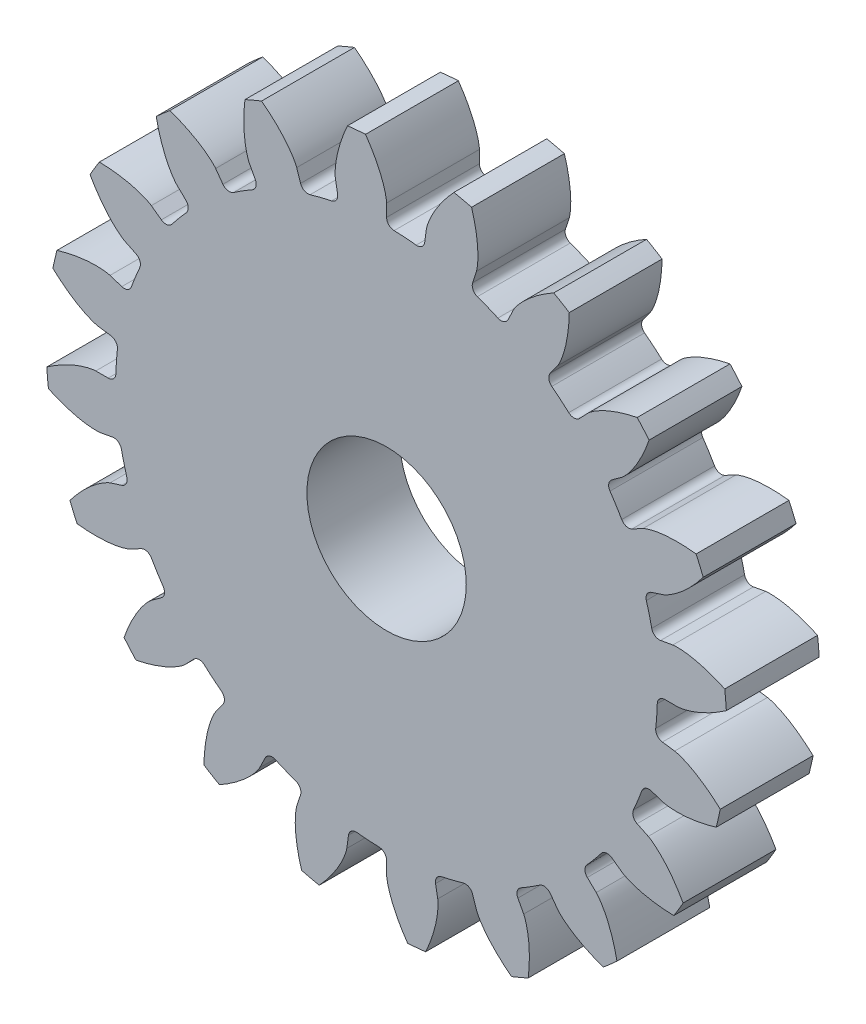
from build123d import *

# Parameters (mm, degrees)
BOSS_EXTRUDE3_DEPTH       = 3
FILLET1_R                 = 0.25
CIRPATTERN8_COUNT         = 20
CIRPATTERN8_COPY_1_DEPTH  = 3
CIRPATTERN8_COPY_2_DEPTH  = 3
CIRPATTERN8_COPY_3_DEPTH  = 3
CIRPATTERN8_COPY_4_DEPTH  = 3
CIRPATTERN8_COPY_5_DEPTH  = 3
CIRPATTERN8_COPY_6_DEPTH  = 3
CIRPATTERN8_COPY_7_DEPTH  = 3
CIRPATTERN8_COPY_8_DEPTH  = 3
CIRPATTERN8_COPY_9_DEPTH  = 3
CIRPATTERN8_COPY_10_DEPTH = 3
CIRPATTERN8_COPY_11_DEPTH = 3
CIRPATTERN8_COPY_12_DEPTH = 3
CIRPATTERN8_COPY_13_DEPTH = 3
CIRPATTERN8_COPY_14_DEPTH = 3
CIRPATTERN8_COPY_15_DEPTH = 3
CIRPATTERN8_COPY_16_DEPTH = 3
CIRPATTERN8_COPY_17_DEPTH = 3
CIRPATTERN8_COPY_18_DEPTH = 3
CIRPATTERN8_COPY_19_DEPTH = 3
FILLET1_OF_CIRPATTERN8_R  = 0.25
SKETCH3_R                 = 2.575
CUT_EXTRUDE2_DEPTH        = 4.0000001


with BuildPart() as part:
    # Sketch1 → Boss-Extrude3 (new body)
    with BuildSketch(Plane.XY):
        with BuildLine():
            Line((8.75, 0), (9.396926208, 0))
            add(Edge.make_bspline(
                [(9.396926208, 0), (9.403873385, 0.000147014), (9.423343335, 0.001014311), (9.460070906, 0.004449694), (9.519753567, 0.012596883), (9.595337479, 0.026698157), (9.692315433, 0.04916848), (9.805467589, 0.081058111), (9.928458206, 0.121729349), (10.060578251, 0.171978374), (10.190725417, 0.227360837), (10.318851863, 0.287431588), (10.444850985, 0.351585639), (10.595383311, 0.434313207), (10.745012763, 0.523787061), (10.861917766, 0.599620812), (10.947597548, 0.658189386), (10.978959632, 0.680033385)],
                knots=[0, 0, 0, 0, 0, 0.005376748, 0.015083688, 0.02853182, 0.046610139, 0.064854849, 0.092110525, 0.119476175, 0.146842495, 0.174208853, 0.201574955, 0.228941013, 0.256307345, 0.307035032, 0.336624535, 0.336624535, 0.336624535, 0.336624535, 0.336624535], degree=4))
            ThreePointArc((10.978959632, 0.680033385), (10.968951272, 0.825898301), (10.957005057, 0.971617307))
            Line((10.957005057, 0.971617307), (8.715799477, 0.772877403))
            ThreePointArc((8.715799477, 0.772877403), (8.741445688, 0.386816868), (8.75, 0))
        make_face()
        with BuildLine():
            ThreePointArc((-8.715799477, -0.772877403), (0.386816868, -8.741445688), (8.75, 0))
            ThreePointArc((8.75, 0), (8.741445688, 0.386816868), (8.715799477, 0.772877403))
            Line((8.715799477, 0.772877403), (-8.715799477, -0.772877403))
        make_face()
        with BuildLine():
            Line((-8.715799477, -0.772877403), (8.715799477, 0.772877403))
            ThreePointArc((8.715799477, 0.772877403), (-0.772877403, 8.715799477), (-8.715799477, -0.772877403))
        make_face()
    boss_extrude3 = extrude(amount=BOSS_EXTRUDE3_DEPTH)

    # Mirror2: Boss-Extrude3 across plane
    add(boss_extrude3.mirror(Plane(origin=(0, 0, 3), x_dir=(0, 0, 1), z_dir=(0.088328846, -0.996091369, 0))))

    # Fillet1
    fillet1_edges = [part.edges().sort_by_distance(p)[0] for p in [
        (8.75, 0, 1.5),
        (8.613465262, 1.539713021, 1.5),
    ]]
    fillet(fillet1_edges, radius=FILLET1_R)

    # CirPattern8: Boss-Extrude3 ×20 about axis
    cirpattern8_axis = Axis((0, 0, 3), (0, 0, -1))
    for i in range(1, CIRPATTERN8_COUNT):
        add(boss_extrude3.rotate(cirpattern8_axis, i * 360 / CIRPATTERN8_COUNT))

    # CirPattern8 copy 1 sketch → CirPattern8 copy 1 (add)
    with BuildSketch(Plane(origin=(0, 0, 0), x_dir=(0.990593115, -0.136840348, 0), z_dir=(0, 0, 1))):
        with BuildLine():
            Line((8.75, 0), (9.396926208, 0))
            add(Edge.make_bspline(
                [(9.396926208, 0), (9.403873385, -0.000147014), (9.423343335, -0.001014311), (9.460070906, -0.004449694), (9.519753567, -0.012596883), (9.595337479, -0.026698157), (9.692315433, -0.04916848), (9.805467589, -0.081058111), (9.928458206, -0.121729349), (10.060578251, -0.171978374), (10.190725417, -0.227360837), (10.318851863, -0.287431588), (10.444850985, -0.351585639), (10.595383311, -0.434313207), (10.745012763, -0.523787061), (10.861917766, -0.599620812), (10.947597548, -0.658189386), (10.978959632, -0.680033385)],
                knots=[0, 0, 0, 0, 0, 0.005376748, 0.015083688, 0.02853182, 0.046610139, 0.064854849, 0.092110525, 0.119476175, 0.146842495, 0.174208853, 0.201574955, 0.228941013, 0.256307345, 0.307035032, 0.336624535, 0.336624535, 0.336624535, 0.336624535, 0.336624535], degree=4))
            ThreePointArc((10.978959632, -0.680033385), (10.968951272, -0.825898301), (10.957005057, -0.971617307))
            Line((10.957005057, -0.971617307), (8.715799477, -0.772877403))
            ThreePointArc((8.715799477, -0.772877403), (8.741445688, -0.386816868), (8.75, 0))
        make_face()
        with BuildLine():
            ThreePointArc((-8.715799477, 0.772877403), (0.386816868, 8.741445688), (8.75, 0))
            ThreePointArc((8.75, 0), (8.741445688, -0.386816868), (8.715799477, -0.772877403))
            Line((8.715799477, -0.772877403), (-8.715799477, 0.772877403))
        make_face()
        with BuildLine():
            Line((-8.715799477, 0.772877403), (8.715799477, -0.772877403))
            ThreePointArc((8.715799477, -0.772877403), (-0.772877403, -8.715799477), (-8.715799477, 0.772877403))
        make_face()
    extrude(amount=CIRPATTERN8_COPY_1_DEPTH)

    # CirPattern8 copy 2 sketch → CirPattern8 copy 2 (add)
    with BuildSketch(Plane(origin=(0, 0, 0), x_dir=(0.899824044, -0.436253012, 0), z_dir=(0, 0, 1))):
        with BuildLine():
            Line((8.75, 0), (9.396926208, 0))
            add(Edge.make_bspline(
                [(9.396926208, 0), (9.403873385, -0.000147014), (9.423343335, -0.001014311), (9.460070906, -0.004449694), (9.519753567, -0.012596883), (9.595337479, -0.026698157), (9.692315433, -0.04916848), (9.805467589, -0.081058111), (9.928458206, -0.121729349), (10.060578251, -0.171978374), (10.190725417, -0.227360837), (10.318851863, -0.287431588), (10.444850985, -0.351585639), (10.595383311, -0.434313207), (10.745012763, -0.523787061), (10.861917766, -0.599620812), (10.947597548, -0.658189386), (10.978959632, -0.680033385)],
                knots=[0, 0, 0, 0, 0, 0.005376748, 0.015083688, 0.02853182, 0.046610139, 0.064854849, 0.092110525, 0.119476175, 0.146842495, 0.174208853, 0.201574955, 0.228941013, 0.256307345, 0.307035032, 0.336624535, 0.336624535, 0.336624535, 0.336624535, 0.336624535], degree=4))
            ThreePointArc((10.978959632, -0.680033385), (10.968951272, -0.825898301), (10.957005057, -0.971617307))
            Line((10.957005057, -0.971617307), (8.715799477, -0.772877403))
            ThreePointArc((8.715799477, -0.772877403), (8.741445688, -0.386816868), (8.75, 0))
        make_face()
        with BuildLine():
            ThreePointArc((-8.715799477, 0.772877403), (0.386816868, 8.741445688), (8.75, 0))
            ThreePointArc((8.75, 0), (8.741445688, -0.386816868), (8.715799477, -0.772877403))
            Line((8.715799477, -0.772877403), (-8.715799477, 0.772877403))
        make_face()
        with BuildLine():
            Line((-8.715799477, 0.772877403), (8.715799477, -0.772877403))
            ThreePointArc((8.715799477, -0.772877403), (-0.772877403, -8.715799477), (-8.715799477, 0.772877403))
        make_face()
    extrude(amount=CIRPATTERN8_COPY_2_DEPTH)

    # CirPattern8 copy 3 sketch → CirPattern8 copy 3 (add)
    with BuildSketch(Plane(origin=(0, 0, 0), x_dir=(0.720973926, -0.692962191, 0), z_dir=(0, 0, 1))):
        with BuildLine():
            Line((8.75, 0), (9.396926208, 0))
            add(Edge.make_bspline(
                [(9.396926208, 0), (9.403873385, -0.000147014), (9.423343335, -0.001014311), (9.460070906, -0.004449694), (9.519753567, -0.012596883), (9.595337479, -0.026698157), (9.692315433, -0.04916848), (9.805467589, -0.081058111), (9.928458206, -0.121729349), (10.060578251, -0.171978374), (10.190725417, -0.227360837), (10.318851863, -0.287431588), (10.444850985, -0.351585639), (10.595383311, -0.434313207), (10.745012763, -0.523787061), (10.861917766, -0.599620812), (10.947597548, -0.658189386), (10.978959632, -0.680033385)],
                knots=[0, 0, 0, 0, 0, 0.005376748, 0.015083688, 0.02853182, 0.046610139, 0.064854849, 0.092110525, 0.119476175, 0.146842495, 0.174208853, 0.201574955, 0.228941013, 0.256307345, 0.307035032, 0.336624535, 0.336624535, 0.336624535, 0.336624535, 0.336624535], degree=4))
            ThreePointArc((10.978959632, -0.680033385), (10.968951272, -0.825898301), (10.957005057, -0.971617307))
            Line((10.957005057, -0.971617307), (8.715799477, -0.772877403))
            ThreePointArc((8.715799477, -0.772877403), (8.741445688, -0.386816868), (8.75, 0))
        make_face()
        with BuildLine():
            ThreePointArc((-8.715799477, 0.772877403), (0.386816868, 8.741445688), (8.75, 0))
            ThreePointArc((8.75, 0), (8.741445688, -0.386816868), (8.715799477, -0.772877403))
            Line((8.715799477, -0.772877403), (-8.715799477, 0.772877403))
        make_face()
        with BuildLine():
            Line((-8.715799477, 0.772877403), (8.715799477, -0.772877403))
            ThreePointArc((8.715799477, -0.772877403), (-0.772877403, -8.715799477), (-8.715799477, 0.772877403))
        make_face()
    extrude(amount=CIRPATTERN8_COPY_3_DEPTH)

    # CirPattern8 copy 4 sketch → CirPattern8 copy 4 (add)
    with BuildSketch(Plane(origin=(0, 0, 0), x_dir=(0.471549857, -0.881839403, 0), z_dir=(0, 0, 1))):
        with BuildLine():
            Line((8.75, 0), (9.396926208, 0))
            add(Edge.make_bspline(
                [(9.396926208, 0), (9.403873385, -0.000147014), (9.423343335, -0.001014311), (9.460070906, -0.004449694), (9.519753567, -0.012596883), (9.595337479, -0.026698157), (9.692315433, -0.04916848), (9.805467589, -0.081058111), (9.928458206, -0.121729349), (10.060578251, -0.171978374), (10.190725417, -0.227360837), (10.318851863, -0.287431588), (10.444850985, -0.351585639), (10.595383311, -0.434313207), (10.745012763, -0.523787061), (10.861917766, -0.599620812), (10.947597548, -0.658189386), (10.978959632, -0.680033385)],
                knots=[0, 0, 0, 0, 0, 0.005376748, 0.015083688, 0.02853182, 0.046610139, 0.064854849, 0.092110525, 0.119476175, 0.146842495, 0.174208853, 0.201574955, 0.228941013, 0.256307345, 0.307035032, 0.336624535, 0.336624535, 0.336624535, 0.336624535, 0.336624535], degree=4))
            ThreePointArc((10.978959632, -0.680033385), (10.968951272, -0.825898301), (10.957005057, -0.971617307))
            Line((10.957005057, -0.971617307), (8.715799477, -0.772877403))
            ThreePointArc((8.715799477, -0.772877403), (8.741445688, -0.386816868), (8.75, 0))
        make_face()
        with BuildLine():
            ThreePointArc((-8.715799477, 0.772877403), (0.386816868, 8.741445688), (8.75, 0))
            ThreePointArc((8.75, 0), (8.741445688, -0.386816868), (8.715799477, -0.772877403))
            Line((8.715799477, -0.772877403), (-8.715799477, 0.772877403))
        make_face()
        with BuildLine():
            Line((-8.715799477, 0.772877403), (8.715799477, -0.772877403))
            ThreePointArc((8.715799477, -0.772877403), (-0.772877403, -8.715799477), (-8.715799477, 0.772877403))
        make_face()
    extrude(amount=CIRPATTERN8_COPY_4_DEPTH)

    # CirPattern8 copy 5 sketch → CirPattern8 copy 5 (add)
    with BuildSketch(Plane(origin=(0, 0, 0), x_dir=(0.175967202, -0.98439603, 0), z_dir=(0, 0, 1))):
        with BuildLine():
            Line((8.75, 0), (9.396926208, 0))
            add(Edge.make_bspline(
                [(9.396926208, 0), (9.403873385, -0.000147014), (9.423343335, -0.001014311), (9.460070906, -0.004449694), (9.519753567, -0.012596883), (9.595337479, -0.026698157), (9.692315433, -0.04916848), (9.805467589, -0.081058111), (9.928458206, -0.121729349), (10.060578251, -0.171978374), (10.190725417, -0.227360837), (10.318851863, -0.287431588), (10.444850985, -0.351585639), (10.595383311, -0.434313207), (10.745012763, -0.523787061), (10.861917766, -0.599620812), (10.947597548, -0.658189386), (10.978959632, -0.680033385)],
                knots=[0, 0, 0, 0, 0, 0.005376748, 0.015083688, 0.02853182, 0.046610139, 0.064854849, 0.092110525, 0.119476175, 0.146842495, 0.174208853, 0.201574955, 0.228941013, 0.256307345, 0.307035032, 0.336624535, 0.336624535, 0.336624535, 0.336624535, 0.336624535], degree=4))
            ThreePointArc((10.978959632, -0.680033385), (10.968951272, -0.825898301), (10.957005057, -0.971617307))
            Line((10.957005057, -0.971617307), (8.715799477, -0.772877403))
            ThreePointArc((8.715799477, -0.772877403), (8.741445688, -0.386816868), (8.75, 0))
        make_face()
        with BuildLine():
            ThreePointArc((-8.715799477, 0.772877403), (0.386816868, 8.741445688), (8.75, 0))
            ThreePointArc((8.75, 0), (8.741445688, -0.386816868), (8.715799477, -0.772877403))
            Line((8.715799477, -0.772877403), (-8.715799477, 0.772877403))
        make_face()
        with BuildLine():
            Line((-8.715799477, 0.772877403), (8.715799477, -0.772877403))
            ThreePointArc((8.715799477, -0.772877403), (-0.772877403, -8.715799477), (-8.715799477, 0.772877403))
        make_face()
    extrude(amount=CIRPATTERN8_COPY_5_DEPTH)

    # CirPattern8 copy 6 sketch → CirPattern8 copy 6 (add)
    with BuildSketch(Plane(origin=(0, 0, 0), x_dir=(-0.136840348, -0.990593115, 0), z_dir=(0, 0, 1))):
        with BuildLine():
            Line((8.75, 0), (9.396926208, 0))
            add(Edge.make_bspline(
                [(9.396926208, 0), (9.403873385, -0.000147014), (9.423343335, -0.001014311), (9.460070906, -0.004449694), (9.519753567, -0.012596883), (9.595337479, -0.026698157), (9.692315433, -0.04916848), (9.805467589, -0.081058111), (9.928458206, -0.121729349), (10.060578251, -0.171978374), (10.190725417, -0.227360837), (10.318851863, -0.287431588), (10.444850985, -0.351585639), (10.595383311, -0.434313207), (10.745012763, -0.523787061), (10.861917766, -0.599620812), (10.947597548, -0.658189386), (10.978959632, -0.680033385)],
                knots=[0, 0, 0, 0, 0, 0.005376748, 0.015083688, 0.02853182, 0.046610139, 0.064854849, 0.092110525, 0.119476175, 0.146842495, 0.174208853, 0.201574955, 0.228941013, 0.256307345, 0.307035032, 0.336624535, 0.336624535, 0.336624535, 0.336624535, 0.336624535], degree=4))
            ThreePointArc((10.978959632, -0.680033385), (10.968951272, -0.825898301), (10.957005057, -0.971617307))
            Line((10.957005057, -0.971617307), (8.715799477, -0.772877403))
            ThreePointArc((8.715799477, -0.772877403), (8.741445688, -0.386816868), (8.75, 0))
        make_face()
        with BuildLine():
            ThreePointArc((-8.715799477, 0.772877403), (0.386816868, 8.741445688), (8.75, 0))
            ThreePointArc((8.75, 0), (8.741445688, -0.386816868), (8.715799477, -0.772877403))
            Line((8.715799477, -0.772877403), (-8.715799477, 0.772877403))
        make_face()
        with BuildLine():
            Line((-8.715799477, 0.772877403), (8.715799477, -0.772877403))
            ThreePointArc((8.715799477, -0.772877403), (-0.772877403, -8.715799477), (-8.715799477, 0.772877403))
        make_face()
    extrude(amount=CIRPATTERN8_COPY_6_DEPTH)

    # CirPattern8 copy 7 sketch → CirPattern8 copy 7 (add)
    with BuildSketch(Plane(origin=(0, 0, 0), x_dir=(-0.436253012, -0.899824044, 0), z_dir=(0, 0, 1))):
        with BuildLine():
            Line((8.75, 0), (9.396926208, 0))
            add(Edge.make_bspline(
                [(9.396926208, 0), (9.403873385, -0.000147014), (9.423343335, -0.001014311), (9.460070906, -0.004449694), (9.519753567, -0.012596883), (9.595337479, -0.026698157), (9.692315433, -0.04916848), (9.805467589, -0.081058111), (9.928458206, -0.121729349), (10.060578251, -0.171978374), (10.190725417, -0.227360837), (10.318851863, -0.287431588), (10.444850985, -0.351585639), (10.595383311, -0.434313207), (10.745012763, -0.523787061), (10.861917766, -0.599620812), (10.947597548, -0.658189386), (10.978959632, -0.680033385)],
                knots=[0, 0, 0, 0, 0, 0.005376748, 0.015083688, 0.02853182, 0.046610139, 0.064854849, 0.092110525, 0.119476175, 0.146842495, 0.174208853, 0.201574955, 0.228941013, 0.256307345, 0.307035032, 0.336624535, 0.336624535, 0.336624535, 0.336624535, 0.336624535], degree=4))
            ThreePointArc((10.978959632, -0.680033385), (10.968951272, -0.825898301), (10.957005057, -0.971617307))
            Line((10.957005057, -0.971617307), (8.715799477, -0.772877403))
            ThreePointArc((8.715799477, -0.772877403), (8.741445688, -0.386816868), (8.75, 0))
        make_face()
        with BuildLine():
            ThreePointArc((-8.715799477, 0.772877403), (0.386816868, 8.741445688), (8.75, 0))
            ThreePointArc((8.75, 0), (8.741445688, -0.386816868), (8.715799477, -0.772877403))
            Line((8.715799477, -0.772877403), (-8.715799477, 0.772877403))
        make_face()
        with BuildLine():
            Line((-8.715799477, 0.772877403), (8.715799477, -0.772877403))
            ThreePointArc((8.715799477, -0.772877403), (-0.772877403, -8.715799477), (-8.715799477, 0.772877403))
        make_face()
    extrude(amount=CIRPATTERN8_COPY_7_DEPTH)

    # CirPattern8 copy 8 sketch → CirPattern8 copy 8 (add)
    with BuildSketch(Plane(origin=(0, 0, 0), x_dir=(-0.692962191, -0.720973926, 0), z_dir=(0, 0, 1))):
        with BuildLine():
            Line((8.75, 0), (9.396926208, 0))
            add(Edge.make_bspline(
                [(9.396926208, 0), (9.403873385, -0.000147014), (9.423343335, -0.001014311), (9.460070906, -0.004449694), (9.519753567, -0.012596883), (9.595337479, -0.026698157), (9.692315433, -0.04916848), (9.805467589, -0.081058111), (9.928458206, -0.121729349), (10.060578251, -0.171978374), (10.190725417, -0.227360837), (10.318851863, -0.287431588), (10.444850985, -0.351585639), (10.595383311, -0.434313207), (10.745012763, -0.523787061), (10.861917766, -0.599620812), (10.947597548, -0.658189386), (10.978959632, -0.680033385)],
                knots=[0, 0, 0, 0, 0, 0.005376748, 0.015083688, 0.02853182, 0.046610139, 0.064854849, 0.092110525, 0.119476175, 0.146842495, 0.174208853, 0.201574955, 0.228941013, 0.256307345, 0.307035032, 0.336624535, 0.336624535, 0.336624535, 0.336624535, 0.336624535], degree=4))
            ThreePointArc((10.978959632, -0.680033385), (10.968951272, -0.825898301), (10.957005057, -0.971617307))
            Line((10.957005057, -0.971617307), (8.715799477, -0.772877403))
            ThreePointArc((8.715799477, -0.772877403), (8.741445688, -0.386816868), (8.75, 0))
        make_face()
        with BuildLine():
            ThreePointArc((-8.715799477, 0.772877403), (0.386816868, 8.741445688), (8.75, 0))
            ThreePointArc((8.75, 0), (8.741445688, -0.386816868), (8.715799477, -0.772877403))
            Line((8.715799477, -0.772877403), (-8.715799477, 0.772877403))
        make_face()
        with BuildLine():
            Line((-8.715799477, 0.772877403), (8.715799477, -0.772877403))
            ThreePointArc((8.715799477, -0.772877403), (-0.772877403, -8.715799477), (-8.715799477, 0.772877403))
        make_face()
    extrude(amount=CIRPATTERN8_COPY_8_DEPTH)

    # CirPattern8 copy 9 sketch → CirPattern8 copy 9 (add)
    with BuildSketch(Plane(origin=(0, 0, 0), x_dir=(-0.881839403, -0.471549857, 0), z_dir=(0, 0, 1))):
        with BuildLine():
            Line((8.75, 0), (9.396926208, 0))
            add(Edge.make_bspline(
                [(9.396926208, 0), (9.403873385, -0.000147014), (9.423343335, -0.001014311), (9.460070906, -0.004449694), (9.519753567, -0.012596883), (9.595337479, -0.026698157), (9.692315433, -0.04916848), (9.805467589, -0.081058111), (9.928458206, -0.121729349), (10.060578251, -0.171978374), (10.190725417, -0.227360837), (10.318851863, -0.287431588), (10.444850985, -0.351585639), (10.595383311, -0.434313207), (10.745012763, -0.523787061), (10.861917766, -0.599620812), (10.947597548, -0.658189386), (10.978959632, -0.680033385)],
                knots=[0, 0, 0, 0, 0, 0.005376748, 0.015083688, 0.02853182, 0.046610139, 0.064854849, 0.092110525, 0.119476175, 0.146842495, 0.174208853, 0.201574955, 0.228941013, 0.256307345, 0.307035032, 0.336624535, 0.336624535, 0.336624535, 0.336624535, 0.336624535], degree=4))
            ThreePointArc((10.978959632, -0.680033385), (10.968951272, -0.825898301), (10.957005057, -0.971617307))
            Line((10.957005057, -0.971617307), (8.715799477, -0.772877403))
            ThreePointArc((8.715799477, -0.772877403), (8.741445688, -0.386816868), (8.75, 0))
        make_face()
        with BuildLine():
            ThreePointArc((-8.715799477, 0.772877403), (0.386816868, 8.741445688), (8.75, 0))
            ThreePointArc((8.75, 0), (8.741445688, -0.386816868), (8.715799477, -0.772877403))
            Line((8.715799477, -0.772877403), (-8.715799477, 0.772877403))
        make_face()
        with BuildLine():
            Line((-8.715799477, 0.772877403), (8.715799477, -0.772877403))
            ThreePointArc((8.715799477, -0.772877403), (-0.772877403, -8.715799477), (-8.715799477, 0.772877403))
        make_face()
    extrude(amount=CIRPATTERN8_COPY_9_DEPTH)

    # CirPattern8 copy 10 sketch → CirPattern8 copy 10 (add)
    with BuildSketch(Plane(origin=(0, 0, 0), x_dir=(-0.98439603, -0.175967202, 0), z_dir=(0, 0, 1))):
        with BuildLine():
            Line((8.75, 0), (9.396926208, 0))
            add(Edge.make_bspline(
                [(9.396926208, 0), (9.403873385, -0.000147014), (9.423343335, -0.001014311), (9.460070906, -0.004449694), (9.519753567, -0.012596883), (9.595337479, -0.026698157), (9.692315433, -0.04916848), (9.805467589, -0.081058111), (9.928458206, -0.121729349), (10.060578251, -0.171978374), (10.190725417, -0.227360837), (10.318851863, -0.287431588), (10.444850985, -0.351585639), (10.595383311, -0.434313207), (10.745012763, -0.523787061), (10.861917766, -0.599620812), (10.947597548, -0.658189386), (10.978959632, -0.680033385)],
                knots=[0, 0, 0, 0, 0, 0.005376748, 0.015083688, 0.02853182, 0.046610139, 0.064854849, 0.092110525, 0.119476175, 0.146842495, 0.174208853, 0.201574955, 0.228941013, 0.256307345, 0.307035032, 0.336624535, 0.336624535, 0.336624535, 0.336624535, 0.336624535], degree=4))
            ThreePointArc((10.978959632, -0.680033385), (10.968951272, -0.825898301), (10.957005057, -0.971617307))
            Line((10.957005057, -0.971617307), (8.715799477, -0.772877403))
            ThreePointArc((8.715799477, -0.772877403), (8.741445688, -0.386816868), (8.75, 0))
        make_face()
        with BuildLine():
            ThreePointArc((-8.715799477, 0.772877403), (0.386816868, 8.741445688), (8.75, 0))
            ThreePointArc((8.75, 0), (8.741445688, -0.386816868), (8.715799477, -0.772877403))
            Line((8.715799477, -0.772877403), (-8.715799477, 0.772877403))
        make_face()
        with BuildLine():
            Line((-8.715799477, 0.772877403), (8.715799477, -0.772877403))
            ThreePointArc((8.715799477, -0.772877403), (-0.772877403, -8.715799477), (-8.715799477, 0.772877403))
        make_face()
    extrude(amount=CIRPATTERN8_COPY_10_DEPTH)

    # CirPattern8 copy 11 sketch → CirPattern8 copy 11 (add)
    with BuildSketch(Plane(origin=(0, 0, 0), x_dir=(-0.990593115, 0.136840348, 0), z_dir=(0, 0, 1))):
        with BuildLine():
            Line((8.75, 0), (9.396926208, 0))
            add(Edge.make_bspline(
                [(9.396926208, 0), (9.403873385, -0.000147014), (9.423343335, -0.001014311), (9.460070906, -0.004449694), (9.519753567, -0.012596883), (9.595337479, -0.026698157), (9.692315433, -0.04916848), (9.805467589, -0.081058111), (9.928458206, -0.121729349), (10.060578251, -0.171978374), (10.190725417, -0.227360837), (10.318851863, -0.287431588), (10.444850985, -0.351585639), (10.595383311, -0.434313207), (10.745012763, -0.523787061), (10.861917766, -0.599620812), (10.947597548, -0.658189386), (10.978959632, -0.680033385)],
                knots=[0, 0, 0, 0, 0, 0.005376748, 0.015083688, 0.02853182, 0.046610139, 0.064854849, 0.092110525, 0.119476175, 0.146842495, 0.174208853, 0.201574955, 0.228941013, 0.256307345, 0.307035032, 0.336624535, 0.336624535, 0.336624535, 0.336624535, 0.336624535], degree=4))
            ThreePointArc((10.978959632, -0.680033385), (10.968951272, -0.825898301), (10.957005057, -0.971617307))
            Line((10.957005057, -0.971617307), (8.715799477, -0.772877403))
            ThreePointArc((8.715799477, -0.772877403), (8.741445688, -0.386816868), (8.75, 0))
        make_face()
        with BuildLine():
            ThreePointArc((-8.715799477, 0.772877403), (0.386816868, 8.741445688), (8.75, 0))
            ThreePointArc((8.75, 0), (8.741445688, -0.386816868), (8.715799477, -0.772877403))
            Line((8.715799477, -0.772877403), (-8.715799477, 0.772877403))
        make_face()
        with BuildLine():
            Line((-8.715799477, 0.772877403), (8.715799477, -0.772877403))
            ThreePointArc((8.715799477, -0.772877403), (-0.772877403, -8.715799477), (-8.715799477, 0.772877403))
        make_face()
    extrude(amount=CIRPATTERN8_COPY_11_DEPTH)

    # CirPattern8 copy 12 sketch → CirPattern8 copy 12 (add)
    with BuildSketch(Plane(origin=(0, 0, 0), x_dir=(-0.899824044, 0.436253012, 0), z_dir=(0, 0, 1))):
        with BuildLine():
            Line((8.75, 0), (9.396926208, 0))
            add(Edge.make_bspline(
                [(9.396926208, 0), (9.403873385, -0.000147014), (9.423343335, -0.001014311), (9.460070906, -0.004449694), (9.519753567, -0.012596883), (9.595337479, -0.026698157), (9.692315433, -0.04916848), (9.805467589, -0.081058111), (9.928458206, -0.121729349), (10.060578251, -0.171978374), (10.190725417, -0.227360837), (10.318851863, -0.287431588), (10.444850985, -0.351585639), (10.595383311, -0.434313207), (10.745012763, -0.523787061), (10.861917766, -0.599620812), (10.947597548, -0.658189386), (10.978959632, -0.680033385)],
                knots=[0, 0, 0, 0, 0, 0.005376748, 0.015083688, 0.02853182, 0.046610139, 0.064854849, 0.092110525, 0.119476175, 0.146842495, 0.174208853, 0.201574955, 0.228941013, 0.256307345, 0.307035032, 0.336624535, 0.336624535, 0.336624535, 0.336624535, 0.336624535], degree=4))
            ThreePointArc((10.978959632, -0.680033385), (10.968951272, -0.825898301), (10.957005057, -0.971617307))
            Line((10.957005057, -0.971617307), (8.715799477, -0.772877403))
            ThreePointArc((8.715799477, -0.772877403), (8.741445688, -0.386816868), (8.75, 0))
        make_face()
        with BuildLine():
            ThreePointArc((-8.715799477, 0.772877403), (0.386816868, 8.741445688), (8.75, 0))
            ThreePointArc((8.75, 0), (8.741445688, -0.386816868), (8.715799477, -0.772877403))
            Line((8.715799477, -0.772877403), (-8.715799477, 0.772877403))
        make_face()
        with BuildLine():
            Line((-8.715799477, 0.772877403), (8.715799477, -0.772877403))
            ThreePointArc((8.715799477, -0.772877403), (-0.772877403, -8.715799477), (-8.715799477, 0.772877403))
        make_face()
    extrude(amount=CIRPATTERN8_COPY_12_DEPTH)

    # CirPattern8 copy 13 sketch → CirPattern8 copy 13 (add)
    with BuildSketch(Plane(origin=(0, 0, 0), x_dir=(-0.720973926, 0.692962191, 0), z_dir=(0, 0, 1))):
        with BuildLine():
            Line((8.75, 0), (9.396926208, 0))
            add(Edge.make_bspline(
                [(9.396926208, 0), (9.403873385, -0.000147014), (9.423343335, -0.001014311), (9.460070906, -0.004449694), (9.519753567, -0.012596883), (9.595337479, -0.026698157), (9.692315433, -0.04916848), (9.805467589, -0.081058111), (9.928458206, -0.121729349), (10.060578251, -0.171978374), (10.190725417, -0.227360837), (10.318851863, -0.287431588), (10.444850985, -0.351585639), (10.595383311, -0.434313207), (10.745012763, -0.523787061), (10.861917766, -0.599620812), (10.947597548, -0.658189386), (10.978959632, -0.680033385)],
                knots=[0, 0, 0, 0, 0, 0.005376748, 0.015083688, 0.02853182, 0.046610139, 0.064854849, 0.092110525, 0.119476175, 0.146842495, 0.174208853, 0.201574955, 0.228941013, 0.256307345, 0.307035032, 0.336624535, 0.336624535, 0.336624535, 0.336624535, 0.336624535], degree=4))
            ThreePointArc((10.978959632, -0.680033385), (10.968951272, -0.825898301), (10.957005057, -0.971617307))
            Line((10.957005057, -0.971617307), (8.715799477, -0.772877403))
            ThreePointArc((8.715799477, -0.772877403), (8.741445688, -0.386816868), (8.75, 0))
        make_face()
        with BuildLine():
            ThreePointArc((-8.715799477, 0.772877403), (0.386816868, 8.741445688), (8.75, 0))
            ThreePointArc((8.75, 0), (8.741445688, -0.386816868), (8.715799477, -0.772877403))
            Line((8.715799477, -0.772877403), (-8.715799477, 0.772877403))
        make_face()
        with BuildLine():
            Line((-8.715799477, 0.772877403), (8.715799477, -0.772877403))
            ThreePointArc((8.715799477, -0.772877403), (-0.772877403, -8.715799477), (-8.715799477, 0.772877403))
        make_face()
    extrude(amount=CIRPATTERN8_COPY_13_DEPTH)

    # CirPattern8 copy 14 sketch → CirPattern8 copy 14 (add)
    with BuildSketch(Plane(origin=(0, 0, 0), x_dir=(-0.471549857, 0.881839403, 0), z_dir=(0, 0, 1))):
        with BuildLine():
            Line((8.75, 0), (9.396926208, 0))
            add(Edge.make_bspline(
                [(9.396926208, 0), (9.403873385, -0.000147014), (9.423343335, -0.001014311), (9.460070906, -0.004449694), (9.519753567, -0.012596883), (9.595337479, -0.026698157), (9.692315433, -0.04916848), (9.805467589, -0.081058111), (9.928458206, -0.121729349), (10.060578251, -0.171978374), (10.190725417, -0.227360837), (10.318851863, -0.287431588), (10.444850985, -0.351585639), (10.595383311, -0.434313207), (10.745012763, -0.523787061), (10.861917766, -0.599620812), (10.947597548, -0.658189386), (10.978959632, -0.680033385)],
                knots=[0, 0, 0, 0, 0, 0.005376748, 0.015083688, 0.02853182, 0.046610139, 0.064854849, 0.092110525, 0.119476175, 0.146842495, 0.174208853, 0.201574955, 0.228941013, 0.256307345, 0.307035032, 0.336624535, 0.336624535, 0.336624535, 0.336624535, 0.336624535], degree=4))
            ThreePointArc((10.978959632, -0.680033385), (10.968951272, -0.825898301), (10.957005057, -0.971617307))
            Line((10.957005057, -0.971617307), (8.715799477, -0.772877403))
            ThreePointArc((8.715799477, -0.772877403), (8.741445688, -0.386816868), (8.75, 0))
        make_face()
        with BuildLine():
            ThreePointArc((-8.715799477, 0.772877403), (0.386816868, 8.741445688), (8.75, 0))
            ThreePointArc((8.75, 0), (8.741445688, -0.386816868), (8.715799477, -0.772877403))
            Line((8.715799477, -0.772877403), (-8.715799477, 0.772877403))
        make_face()
        with BuildLine():
            Line((-8.715799477, 0.772877403), (8.715799477, -0.772877403))
            ThreePointArc((8.715799477, -0.772877403), (-0.772877403, -8.715799477), (-8.715799477, 0.772877403))
        make_face()
    extrude(amount=CIRPATTERN8_COPY_14_DEPTH)

    # CirPattern8 copy 15 sketch → CirPattern8 copy 15 (add)
    with BuildSketch(Plane(origin=(0, 0, 0), x_dir=(-0.175967202, 0.98439603, 0), z_dir=(0, 0, 1))):
        with BuildLine():
            Line((8.75, 0), (9.396926208, 0))
            add(Edge.make_bspline(
                [(9.396926208, 0), (9.403873385, -0.000147014), (9.423343335, -0.001014311), (9.460070906, -0.004449694), (9.519753567, -0.012596883), (9.595337479, -0.026698157), (9.692315433, -0.04916848), (9.805467589, -0.081058111), (9.928458206, -0.121729349), (10.060578251, -0.171978374), (10.190725417, -0.227360837), (10.318851863, -0.287431588), (10.444850985, -0.351585639), (10.595383311, -0.434313207), (10.745012763, -0.523787061), (10.861917766, -0.599620812), (10.947597548, -0.658189386), (10.978959632, -0.680033385)],
                knots=[0, 0, 0, 0, 0, 0.005376748, 0.015083688, 0.02853182, 0.046610139, 0.064854849, 0.092110525, 0.119476175, 0.146842495, 0.174208853, 0.201574955, 0.228941013, 0.256307345, 0.307035032, 0.336624535, 0.336624535, 0.336624535, 0.336624535, 0.336624535], degree=4))
            ThreePointArc((10.978959632, -0.680033385), (10.968951272, -0.825898301), (10.957005057, -0.971617307))
            Line((10.957005057, -0.971617307), (8.715799477, -0.772877403))
            ThreePointArc((8.715799477, -0.772877403), (8.741445688, -0.386816868), (8.75, 0))
        make_face()
        with BuildLine():
            ThreePointArc((-8.715799477, 0.772877403), (0.386816868, 8.741445688), (8.75, 0))
            ThreePointArc((8.75, 0), (8.741445688, -0.386816868), (8.715799477, -0.772877403))
            Line((8.715799477, -0.772877403), (-8.715799477, 0.772877403))
        make_face()
        with BuildLine():
            Line((-8.715799477, 0.772877403), (8.715799477, -0.772877403))
            ThreePointArc((8.715799477, -0.772877403), (-0.772877403, -8.715799477), (-8.715799477, 0.772877403))
        make_face()
    extrude(amount=CIRPATTERN8_COPY_15_DEPTH)

    # CirPattern8 copy 16 sketch → CirPattern8 copy 16 (add)
    with BuildSketch(Plane(origin=(0, 0, 0), x_dir=(0.136840348, 0.990593115, 0), z_dir=(0, 0, 1))):
        with BuildLine():
            Line((8.75, 0), (9.396926208, 0))
            add(Edge.make_bspline(
                [(9.396926208, 0), (9.403873385, -0.000147014), (9.423343335, -0.001014311), (9.460070906, -0.004449694), (9.519753567, -0.012596883), (9.595337479, -0.026698157), (9.692315433, -0.04916848), (9.805467589, -0.081058111), (9.928458206, -0.121729349), (10.060578251, -0.171978374), (10.190725417, -0.227360837), (10.318851863, -0.287431588), (10.444850985, -0.351585639), (10.595383311, -0.434313207), (10.745012763, -0.523787061), (10.861917766, -0.599620812), (10.947597548, -0.658189386), (10.978959632, -0.680033385)],
                knots=[0, 0, 0, 0, 0, 0.005376748, 0.015083688, 0.02853182, 0.046610139, 0.064854849, 0.092110525, 0.119476175, 0.146842495, 0.174208853, 0.201574955, 0.228941013, 0.256307345, 0.307035032, 0.336624535, 0.336624535, 0.336624535, 0.336624535, 0.336624535], degree=4))
            ThreePointArc((10.978959632, -0.680033385), (10.968951272, -0.825898301), (10.957005057, -0.971617307))
            Line((10.957005057, -0.971617307), (8.715799477, -0.772877403))
            ThreePointArc((8.715799477, -0.772877403), (8.741445688, -0.386816868), (8.75, 0))
        make_face()
        with BuildLine():
            ThreePointArc((-8.715799477, 0.772877403), (0.386816868, 8.741445688), (8.75, 0))
            ThreePointArc((8.75, 0), (8.741445688, -0.386816868), (8.715799477, -0.772877403))
            Line((8.715799477, -0.772877403), (-8.715799477, 0.772877403))
        make_face()
        with BuildLine():
            Line((-8.715799477, 0.772877403), (8.715799477, -0.772877403))
            ThreePointArc((8.715799477, -0.772877403), (-0.772877403, -8.715799477), (-8.715799477, 0.772877403))
        make_face()
    extrude(amount=CIRPATTERN8_COPY_16_DEPTH)

    # CirPattern8 copy 17 sketch → CirPattern8 copy 17 (add)
    with BuildSketch(Plane(origin=(0, 0, 0), x_dir=(0.436253012, 0.899824044, 0), z_dir=(0, 0, 1))):
        with BuildLine():
            Line((8.75, 0), (9.396926208, 0))
            add(Edge.make_bspline(
                [(9.396926208, 0), (9.403873385, -0.000147014), (9.423343335, -0.001014311), (9.460070906, -0.004449694), (9.519753567, -0.012596883), (9.595337479, -0.026698157), (9.692315433, -0.04916848), (9.805467589, -0.081058111), (9.928458206, -0.121729349), (10.060578251, -0.171978374), (10.190725417, -0.227360837), (10.318851863, -0.287431588), (10.444850985, -0.351585639), (10.595383311, -0.434313207), (10.745012763, -0.523787061), (10.861917766, -0.599620812), (10.947597548, -0.658189386), (10.978959632, -0.680033385)],
                knots=[0, 0, 0, 0, 0, 0.005376748, 0.015083688, 0.02853182, 0.046610139, 0.064854849, 0.092110525, 0.119476175, 0.146842495, 0.174208853, 0.201574955, 0.228941013, 0.256307345, 0.307035032, 0.336624535, 0.336624535, 0.336624535, 0.336624535, 0.336624535], degree=4))
            ThreePointArc((10.978959632, -0.680033385), (10.968951272, -0.825898301), (10.957005057, -0.971617307))
            Line((10.957005057, -0.971617307), (8.715799477, -0.772877403))
            ThreePointArc((8.715799477, -0.772877403), (8.741445688, -0.386816868), (8.75, 0))
        make_face()
        with BuildLine():
            ThreePointArc((-8.715799477, 0.772877403), (0.386816868, 8.741445688), (8.75, 0))
            ThreePointArc((8.75, 0), (8.741445688, -0.386816868), (8.715799477, -0.772877403))
            Line((8.715799477, -0.772877403), (-8.715799477, 0.772877403))
        make_face()
        with BuildLine():
            Line((-8.715799477, 0.772877403), (8.715799477, -0.772877403))
            ThreePointArc((8.715799477, -0.772877403), (-0.772877403, -8.715799477), (-8.715799477, 0.772877403))
        make_face()
    extrude(amount=CIRPATTERN8_COPY_17_DEPTH)

    # CirPattern8 copy 18 sketch → CirPattern8 copy 18 (add)
    with BuildSketch(Plane(origin=(0, 0, 0), x_dir=(0.692962191, 0.720973926, 0), z_dir=(0, 0, 1))):
        with BuildLine():
            Line((8.75, 0), (9.396926208, 0))
            add(Edge.make_bspline(
                [(9.396926208, 0), (9.403873385, -0.000147014), (9.423343335, -0.001014311), (9.460070906, -0.004449694), (9.519753567, -0.012596883), (9.595337479, -0.026698157), (9.692315433, -0.04916848), (9.805467589, -0.081058111), (9.928458206, -0.121729349), (10.060578251, -0.171978374), (10.190725417, -0.227360837), (10.318851863, -0.287431588), (10.444850985, -0.351585639), (10.595383311, -0.434313207), (10.745012763, -0.523787061), (10.861917766, -0.599620812), (10.947597548, -0.658189386), (10.978959632, -0.680033385)],
                knots=[0, 0, 0, 0, 0, 0.005376748, 0.015083688, 0.02853182, 0.046610139, 0.064854849, 0.092110525, 0.119476175, 0.146842495, 0.174208853, 0.201574955, 0.228941013, 0.256307345, 0.307035032, 0.336624535, 0.336624535, 0.336624535, 0.336624535, 0.336624535], degree=4))
            ThreePointArc((10.978959632, -0.680033385), (10.968951272, -0.825898301), (10.957005057, -0.971617307))
            Line((10.957005057, -0.971617307), (8.715799477, -0.772877403))
            ThreePointArc((8.715799477, -0.772877403), (8.741445688, -0.386816868), (8.75, 0))
        make_face()
        with BuildLine():
            ThreePointArc((-8.715799477, 0.772877403), (0.386816868, 8.741445688), (8.75, 0))
            ThreePointArc((8.75, 0), (8.741445688, -0.386816868), (8.715799477, -0.772877403))
            Line((8.715799477, -0.772877403), (-8.715799477, 0.772877403))
        make_face()
        with BuildLine():
            Line((-8.715799477, 0.772877403), (8.715799477, -0.772877403))
            ThreePointArc((8.715799477, -0.772877403), (-0.772877403, -8.715799477), (-8.715799477, 0.772877403))
        make_face()
    extrude(amount=CIRPATTERN8_COPY_18_DEPTH)

    # CirPattern8 copy 19 sketch → CirPattern8 copy 19 (add)
    with BuildSketch(Plane(origin=(0, 0, 0), x_dir=(0.881839403, 0.471549857, 0), z_dir=(0, 0, 1))):
        with BuildLine():
            Line((8.75, 0), (9.396926208, 0))
            add(Edge.make_bspline(
                [(9.396926208, 0), (9.403873385, -0.000147014), (9.423343335, -0.001014311), (9.460070906, -0.004449694), (9.519753567, -0.012596883), (9.595337479, -0.026698157), (9.692315433, -0.04916848), (9.805467589, -0.081058111), (9.928458206, -0.121729349), (10.060578251, -0.171978374), (10.190725417, -0.227360837), (10.318851863, -0.287431588), (10.444850985, -0.351585639), (10.595383311, -0.434313207), (10.745012763, -0.523787061), (10.861917766, -0.599620812), (10.947597548, -0.658189386), (10.978959632, -0.680033385)],
                knots=[0, 0, 0, 0, 0, 0.005376748, 0.015083688, 0.02853182, 0.046610139, 0.064854849, 0.092110525, 0.119476175, 0.146842495, 0.174208853, 0.201574955, 0.228941013, 0.256307345, 0.307035032, 0.336624535, 0.336624535, 0.336624535, 0.336624535, 0.336624535], degree=4))
            ThreePointArc((10.978959632, -0.680033385), (10.968951272, -0.825898301), (10.957005057, -0.971617307))
            Line((10.957005057, -0.971617307), (8.715799477, -0.772877403))
            ThreePointArc((8.715799477, -0.772877403), (8.741445688, -0.386816868), (8.75, 0))
        make_face()
        with BuildLine():
            ThreePointArc((-8.715799477, 0.772877403), (0.386816868, 8.741445688), (8.75, 0))
            ThreePointArc((8.75, 0), (8.741445688, -0.386816868), (8.715799477, -0.772877403))
            Line((8.715799477, -0.772877403), (-8.715799477, 0.772877403))
        make_face()
        with BuildLine():
            Line((-8.715799477, 0.772877403), (8.715799477, -0.772877403))
            ThreePointArc((8.715799477, -0.772877403), (-0.772877403, -8.715799477), (-8.715799477, 0.772877403))
        make_face()
    extrude(amount=CIRPATTERN8_COPY_19_DEPTH)

    # Fillet1 of CirPattern8
    fillet1_of_cirpattern8_edges = [part.edges().sort_by_distance(p)[0] for p in [
        (8.321744518, -2.703898701, 1.5),
        (8.667689755, -1.197353044, 1.5),
        (7.078898701, -5.143120958, 1.5),
        (7.873460384, -3.817213851, 1.5),
        (5.143120958, -7.078898701, 1.5),
        (6.308521853, -6.06341917, 1.5),
        (2.703898701, -8.321744518, 1.5),
        (4.126061248, -7.716094775, 1.5),
        (0, -8.75, 1.5),
        (1.539713021, -8.613465262, 1.5),
        (-2.703898701, -8.321744518, 1.5),
        (-1.197353044, -8.667689755, 1.5),
        (-5.143120958, -7.078898701, 1.5),
        (-3.817213851, -7.873460384, 1.5),
        (-7.078898701, -5.143120958, 1.5),
        (-6.06341917, -6.308521853, 1.5),
        (-8.321744518, -2.703898701, 1.5),
        (-7.716094775, -4.126061248, 1.5),
        (-8.75, 0, 1.5),
        (-8.613465262, -1.539713021, 1.5),
        (-8.321744518, 2.703898701, 1.5),
        (-8.667689755, 1.197353044, 1.5),
        (-7.078898701, 5.143120958, 1.5),
        (-7.873460384, 3.817213851, 1.5),
        (-5.143120958, 7.078898701, 1.5),
        (-6.308521853, 6.06341917, 1.5),
        (-2.703898701, 8.321744518, 1.5),
        (-4.126061248, 7.716094775, 1.5),
        (0, 8.75, 1.5),
        (-1.539713021, 8.613465262, 1.5),
        (2.703898701, 8.321744518, 1.5),
        (1.197353044, 8.667689755, 1.5),
        (5.143120958, 7.078898701, 1.5),
        (3.817213851, 7.873460384, 1.5),
        (7.078898701, 5.143120958, 1.5),
        (6.06341917, 6.308521853, 1.5),
        (8.321744518, 2.703898701, 1.5),
        (7.716094775, 4.126061248, 1.5),
    ]]
    fillet(fillet1_of_cirpattern8_edges, radius=FILLET1_OF_CIRPATTERN8_R)

    # Sketch3 → Cut-Extrude2 (cut, through all)
    with BuildSketch(Plane.XY.offset(3)):
        Circle(SKETCH3_R)
    extrude(amount=-CUT_EXTRUDE2_DEPTH, mode=Mode.SUBTRACT)


solid = part.part
